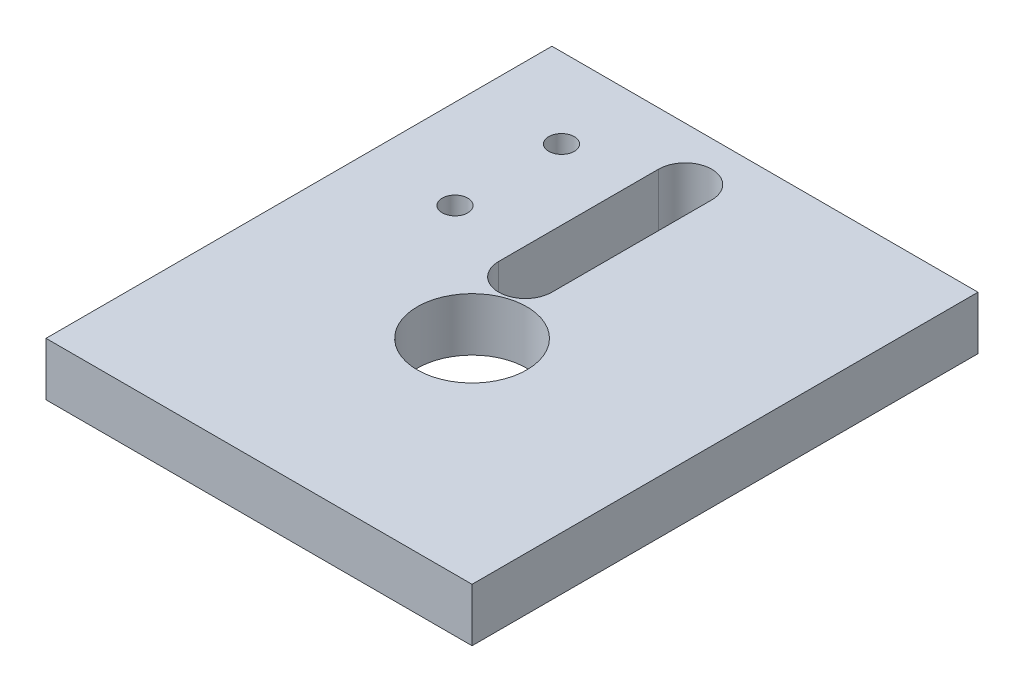
from build123d import *

# Parameters (mm, degrees)
SKETCH1_W                   = 25.4
SKETCH1_H                   = 30.1625
SKETCH1_R                   = 0.762
BOSS_EXTRUDE1_DEPTH         = 3.175
F_1_4_CLEARANCE_HOLE1_D     = 6.5278
F_1_4_CLEARANCE_HOLE1_DEPTH = 6.35
F_1_4_CLEARANCE_HOLE1_TIP   = 1.961148974


with BuildPart() as part:
    # Sketch1 → Boss-Extrude1 (new body)
    with BuildSketch(Plane(origin=(0, 0, 0), x_dir=(1, 0, 0), z_dir=(0, 1, 0))):
        Rectangle(SKETCH1_W, SKETCH1_H)
        with Locations((-7.366, 3.96875)):
            Circle(SKETCH1_R, mode=Mode.SUBTRACT)
        with Locations((-7.366, 10.31875)):
            Circle(SKETCH1_R, mode=Mode.SUBTRACT)
        with BuildLine():
            Line((0, 11.90625), (0, 2.38125))
            ThreePointArc((0, 2.38125), (-1.5875, 0.79375), (-3.175, 2.38125))
            Line((-3.175, 2.38125), (-3.175, 11.90625))
            ThreePointArc((-3.175, 11.90625), (-1.5875, 13.49375), (0, 11.90625))
        make_face(mode=Mode.SUBTRACT)
    extrude(amount=BOSS_EXTRUDE1_DEPTH)

    # 1/4 Clearance Hole1
    with Locations(Plane(origin=(0, 3.175, 0), x_dir=(1, 0, 0), z_dir=(0, 1, 0))):
        with Locations((0, -2.38125)):
            Hole(F_1_4_CLEARANCE_HOLE1_D / 2, depth=F_1_4_CLEARANCE_HOLE1_DEPTH)
            with Locations((0, 0, -(F_1_4_CLEARANCE_HOLE1_DEPTH + F_1_4_CLEARANCE_HOLE1_TIP / 2))):  # 118° drill point
                Cone(0, F_1_4_CLEARANCE_HOLE1_D / 2, F_1_4_CLEARANCE_HOLE1_TIP, mode=Mode.SUBTRACT)


solid = part.part
